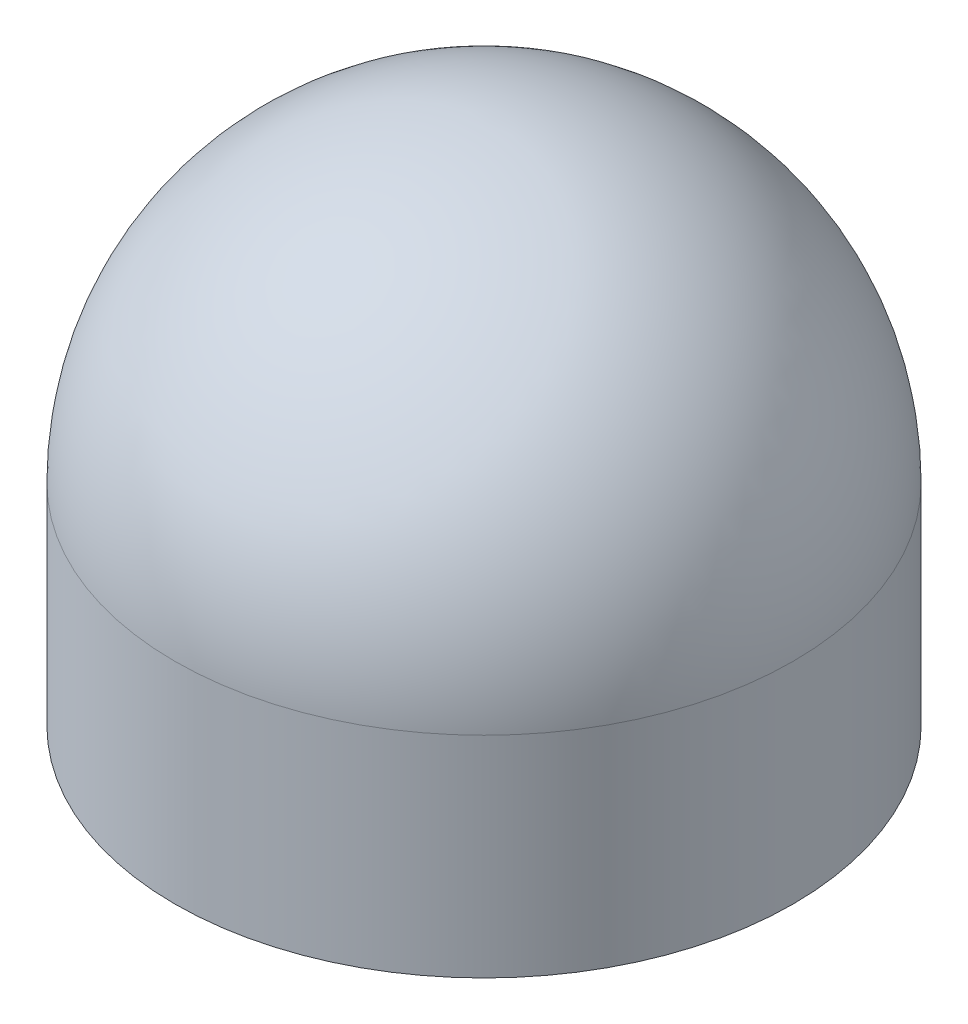
from build123d import *

# Parameters (mm, degrees)
SKETCH1_R           = 7.5
BOSS_EXTRUDE1_DEPTH = 12.6
FILLET1_R           = 7.5
SKETCH2_R           = 1.625
CUT_EXTRUDE1_DEPTH  = 12


with BuildPart() as part:
    # Sketch1 → Boss-Extrude1 (new body)
    with BuildSketch(Plane(origin=(0, 0, 0), x_dir=(1, 0, 0), z_dir=(0, 1, 0))):
        Circle(SKETCH1_R)
    extrude(amount=BOSS_EXTRUDE1_DEPTH)

    # Fillet1
    fillet1_edges = [part.edges().sort_by_distance(p)[0] for p in [
        (-7.5, 12.6, 0),
    ]]
    fillet(fillet1_edges, radius=FILLET1_R)

    # Sketch2 → Cut-Extrude1 (cut)
    with BuildSketch(Plane.XZ):
        Circle(SKETCH2_R)
    extrude(amount=-CUT_EXTRUDE1_DEPTH, mode=Mode.SUBTRACT)


solid = part.part
